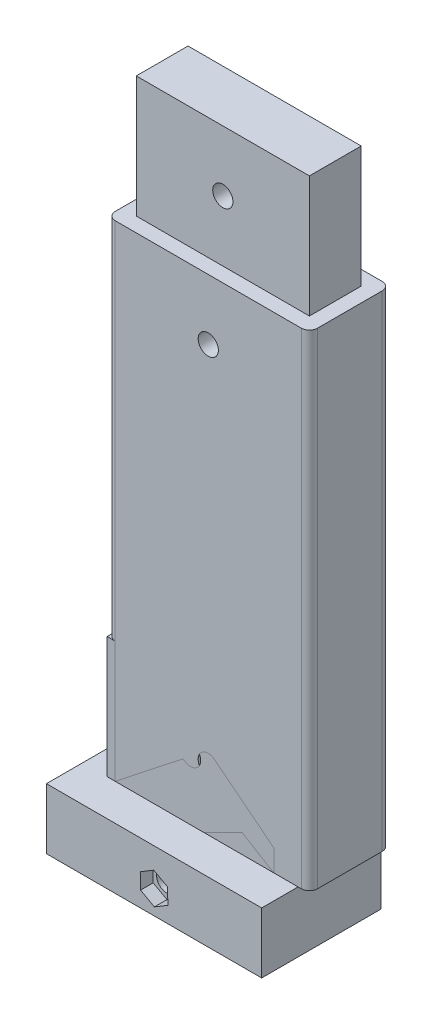
from build123d import *

# Parameters (mm, degrees)
BOSS_EXTRUDE1_DEPTH      = 120
SKETCH3_W                = 42
SKETCH3_H                = 12
CUT_EXTRUDE2_DEPTH       = 30
SKETCH6_R                = 2.5
CUT_EXTRUDE3_DEPTH       = 30
SKETCH8_W                = 42.8
SKETCH8_H                = 12.8
BOSS_EXTRUDE2_DEPTH      = 30
SKETCH9_R                = 2.5
CUT_EXTRUDE4_DEPTH       = 30
SKETCH11_W               = 41.2
SKETCH11_H               = 11.5
BOSS_EXTRUDE3_DEPTH      = 30
BOSS_EXTRUDE4_DEPTH      = 3
BOSS_EXTRUDE4_DEPTH_BACK = 14.5
SKETCH16_W               = 41.2
SKETCH16_H               = 17.5
BOSS_EXTRUDE5_DEPTH      = 15
CUT_EXTRUDE5_DEPTH       = 3.12


with BuildPart() as part:
    # Sketch1 → Boss-Extrude1 (new body)
    with BuildSketch(Plane(origin=(0, 0, 0), x_dir=(1, 0, 0), z_dir=(0, 1, 0))):
        with BuildLine():
            Line((2, 0), (48, 0))
            ThreePointArc((48, 0), (49.414213562, 0.585786438), (50, 2))
            Line((50, 2), (50, 18))
            ThreePointArc((50, 18), (49.414213562, 19.414213562), (48, 20))
            Line((48, 20), (2, 20))
            ThreePointArc((2, 20), (0.585786438, 19.414213562), (0, 18))
            Line((0, 18), (0, 2))
            ThreePointArc((0, 2), (0.585786438, 0.585786438), (2, 0))
        make_face()
    extrude(amount=BOSS_EXTRUDE1_DEPTH)

    # Sketch3 → Cut-Extrude2 (cut)
    with BuildSketch(Plane.XZ):
        with Locations((25, -10)):
            Rectangle(SKETCH3_W, SKETCH3_H)
    extrude(amount=-CUT_EXTRUDE2_DEPTH, mode=Mode.SUBTRACT)

    # Sketch6 → Cut-Extrude3 (cut)
    with BuildSketch(Plane.XY):
        with Locations((25, 105)):
            Circle(SKETCH6_R)
        with Locations((25, 15)):
            Circle(SKETCH6_R)
    extrude(amount=-CUT_EXTRUDE3_DEPTH, mode=Mode.SUBTRACT)

    # Sketch8 → Boss-Extrude2 (add)
    with BuildSketch(Plane(origin=(0, 120, 0), x_dir=(1, 0, 0), z_dir=(0, 1, 0))):
        with Locations((25, 10)):
            Rectangle(SKETCH8_W, SKETCH8_H)
    extrude(amount=BOSS_EXTRUDE2_DEPTH)

    # Sketch9 → Cut-Extrude4 (cut)
    with BuildSketch(Plane.XY.offset(-3.6)):
        with Locations((25, 135)):
            Circle(SKETCH9_R)
    extrude(amount=-CUT_EXTRUDE4_DEPTH, mode=Mode.SUBTRACT)


with BuildPart() as body_2:
    # Sketch11 → Boss-Extrude3 (new body)
    with BuildSketch(Plane(origin=(0, 0, 0), x_dir=(1, 0, 0), z_dir=(0, 1, 0))):
        with Locations((20.6, 5.75)):
            Rectangle(SKETCH11_W, SKETCH11_H)
    extrude(amount=BOSS_EXTRUDE3_DEPTH)

    # Sketch13 → Ø5.0 (5) Diameter Hole1 (revolve, cut)
    with BuildSketch(Plane(origin=(20.6, 15, 0), x_dir=(0, -1, 0), z_dir=(1, 0, 0))):
        Polygon((0, 0), (0, 20), (2.5, 20), (2.5, 0.020977491), (2.525, 0), align=None)
    revolve(axis=Axis((20.6, 15, 6.35), (0, 0, -1)), mode=Mode.SUBTRACT)

    # Sketch15 → Boss-Extrude4 (add, two sides)
    with BuildSketch(Plane.XY) as boss_extrude4_sk:
        with BuildLine():
            Line((0, 0), (0, -15.109741722))
            ThreePointArc((0, -15.109741722), (20.6, -1.159826197), (41.2, -15.109741722))
            Line((41.2, -15.109741722), (41.2, 0))
            Line((41.2, 0), (0, 0))
        make_face()
    extrude(amount=BOSS_EXTRUDE4_DEPTH)
    extrude(boss_extrude4_sk.sketch, amount=-BOSS_EXTRUDE4_DEPTH_BACK)

    # Sketch16 → Boss-Extrude5 (add)
    with BuildSketch(Plane(origin=(0, 0, 0), x_dir=(1, 0, 0), z_dir=(0, 1, 0))):
        Polygon((-6, 20.5), (-6, 11.5), (-6, 0), (-6, -9), (47.2, -9), (47.2, 0), (47.2, 11.5), (47.2, 20.5), align=None)
        with Locations((20.6, 5.75)):
            Rectangle(SKETCH16_W, SKETCH16_H, mode=Mode.SUBTRACT)
    extrude(amount=-BOSS_EXTRUDE5_DEPTH)

    # Sketch18 → Ø5.0 (5) Diameter Hole2 (revolve, cut)
    with BuildSketch(Plane(origin=(20.6, -9.147025383, -20.5), x_dir=(0, 1, 0), z_dir=(1, 0, 0))):
        Polygon((0, 0), (0, 29.5), (2.5, 29.5), (2.5, 0.020977491), (2.525, 0), align=None)
    revolve(axis=Axis((20.6, -9.147025383, -26.85), (0, 0, 1)), mode=Mode.SUBTRACT)

    # Sketch22 → Cut-Extrude5 (cut)
    with BuildSketch(Plane.XY.offset(9)):
        Polygon((24.013806249, -11.026766561), (23.934806737, -7.130453037), (20.521000488, -5.250711859), (17.186193751, -7.267284205), (17.265193263, -11.163597729), (20.678999512, -13.043338907), align=None)
    extrude(amount=-CUT_EXTRUDE5_DEPTH, mode=Mode.SUBTRACT)


solid = Compound([part.part, body_2.part])
